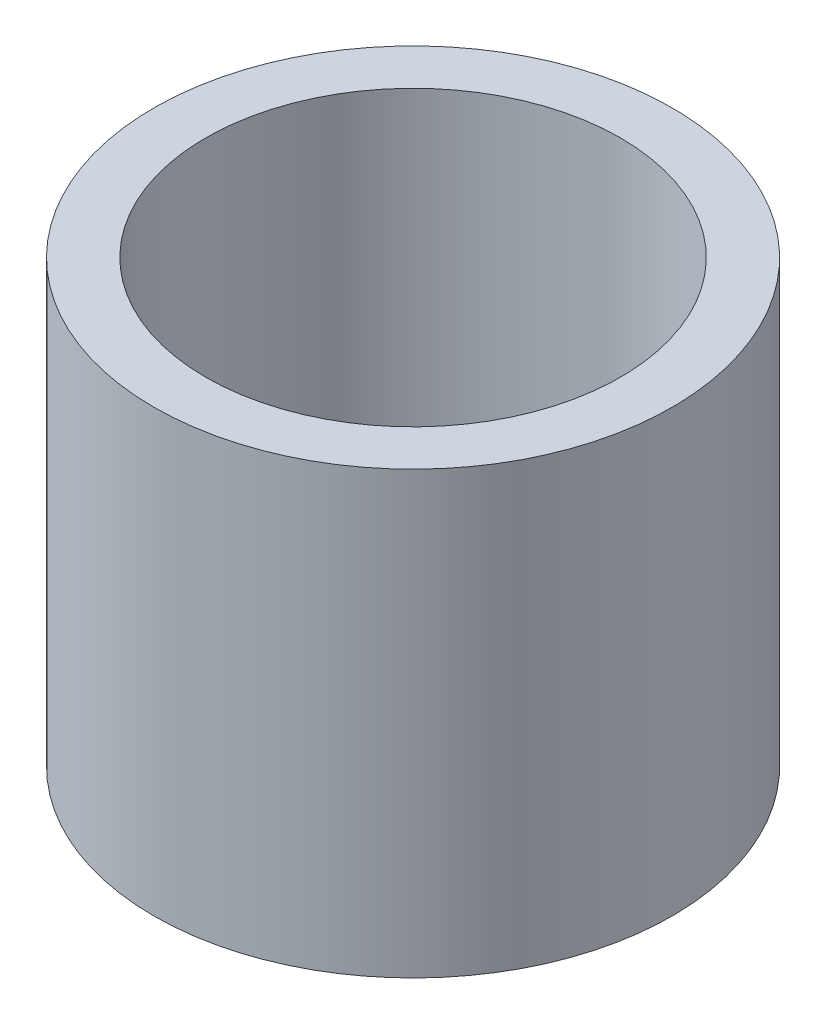
from build123d import *

# Parameters (mm, degrees)
SKETCH1_R           = 20
SKETCH1_R_2         = 16
BOSS_EXTRUDE1_DEPTH = 17


with BuildPart() as part:
    # Sketch1 → Boss-Extrude1 (new body, symmetric)
    with BuildSketch(Plane(origin=(0, 0, 0), x_dir=(1, 0, 0), z_dir=(0, 1, 0))):
        Circle(SKETCH1_R)
        Circle(SKETCH1_R_2, mode=Mode.SUBTRACT)
    extrude(amount=BOSS_EXTRUDE1_DEPTH, both=True)


solid = part.part
